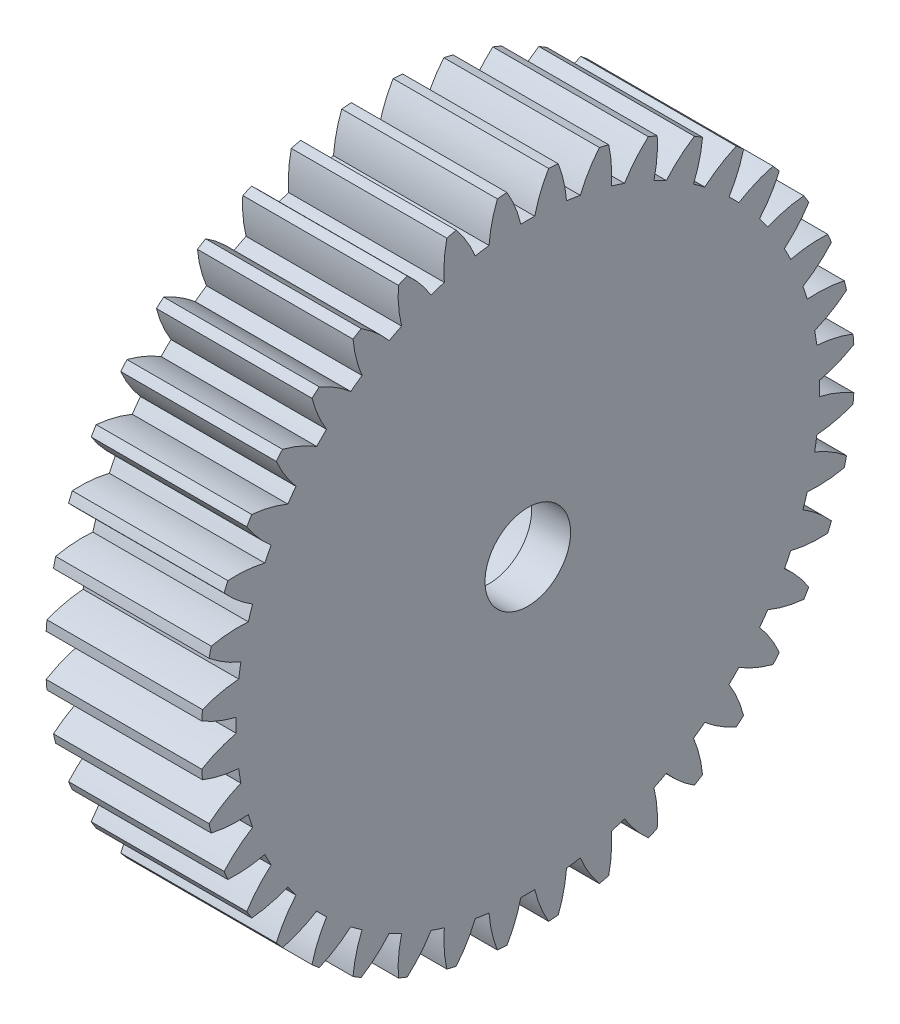
from build123d import *

# Parameters (mm, degrees)
SKETCH1_R           = 0.4
BOSS_EXTRUDE1_DEPTH = 3
SKETCH4_R           = 2.55
CUT_EXTRUDE2_DEPTH  = 4
BOSS_EXTRUDE2_DEPTH = 1
SKETCH6_R           = 1.1
CUT_EXTRUDE4_DEPTH  = 2


with BuildPart() as part:
    # Sketch1 → Boss-Extrude1 (new body)
    with BuildSketch(Plane(origin=(-1.595003587, 0, 0), x_dir=(0, 0, -1), z_dir=(1, 0, 0))):
        with BuildLine():
            ThreePointArc((-8.382899086, 0.535726523), (-7.953265869, 0.324118302), (-7.496863358, 0.178999427))
            ThreePointArc((-7.496863358, 0.178999427), (-7.499, 0), (-7.496863358, -0.178999427))
            ThreePointArc((-7.496863358, -0.178999427), (-7.953265869, -0.324118302), (-8.382899086, -0.535726523))
            ThreePointArc((-8.382899086, -0.535726523), (-8.374105603, -0.659056404), (-8.36349778, -0.782243493))
            ThreePointArc((-8.36349778, -0.782243493), (-7.906051242, -0.924037024), (-7.432566209, -0.995972162))
            ThreePointArc((-7.432566209, -0.995972162), (-7.406674866, -1.173102053), (-7.37656285, -1.349563456))
            ThreePointArc((-7.37656285, -1.349563456), (-7.804644696, -1.564292759), (-8.195885596, -1.840505175))
            ThreePointArc((-8.195885596, -1.840505175), (-8.167907331, -1.960941056), (-8.138159402, -2.080952079))
            ThreePointArc((-8.138159402, -2.080952079), (-7.664163394, -2.149439492), (-7.185254613, -2.146419611))
            ThreePointArc((-7.185254613, -2.146419611), (-7.131972816, -2.317318441), (-7.074626883, -2.486896753))
            ThreePointArc((-7.074626883, -2.486896753), (-7.463847268, -2.765949137), (-7.807062202, -3.099964481))
            ThreePointArc((-7.807062202, -3.099964481), (-7.760588073, -3.214540832), (-7.71243253, -3.328420718))
            ThreePointArc((-7.71243253, -3.328420718), (-7.233558408, -3.321915625), (-6.761018202, -3.244015085))
            ThreePointArc((-6.761018202, -3.244015085), (-6.681657925, -3.404474758), (-6.598490123, -3.562994399))
            ThreePointArc((-6.598490123, -3.562994399), (-6.939265149, -3.899498668), (-7.226003026, -4.283092373))
            ThreePointArc((-7.226003026, -4.283092373), (-7.162177381, -4.388987944), (-7.096799973, -4.493932593))
            ThreePointArc((-7.096799973, -4.493932593), (-6.624839207, -4.412595171), (-6.170303084, -4.261732142))
            ThreePointArc((-6.170303084, -4.261732142), (-6.066818441, -4.407801607), (-5.959876638, -4.551359298))
            ThreePointArc((-5.959876638, -4.551359298), (-6.243815291, -4.9370296), (-6.467015673, -5.360756316))
            ThreePointArc((-6.467015673, -5.360756316), (-6.387410111, -5.455363606), (-6.306420647, -5.548788933))
            ThreePointArc((-6.306420647, -5.548788933), (-5.852994478, -5.39462198), (-5.427654626, -5.174511209))
            ThreePointArc((-5.427654626, -5.174511209), (-5.302593752, -5.302593752), (-5.174511209, -5.427654626))
            ThreePointArc((-5.174511209, -5.427654626), (-5.39462198, -5.852994478), (-5.548788933, -6.306420647))
            ThreePointArc((-5.548788933, -6.306420647), (-5.455363606, -6.387410111), (-5.360756316, -6.467015673))
            ThreePointArc((-5.360756316, -6.467015673), (-4.9370296, -6.243815291), (-4.551359298, -5.959876638))
            ThreePointArc((-4.551359298, -5.959876638), (-4.407801607, -6.066818441), (-4.261732142, -6.170303084))
            ThreePointArc((-4.261732142, -6.170303084), (-4.412595171, -6.624839207), (-4.493932593, -7.096799973))
            ThreePointArc((-4.493932593, -7.096799973), (-4.388987944, -7.162177381), (-4.283092373, -7.226003026))
            ThreePointArc((-4.283092373, -7.226003026), (-3.899498668, -6.939265149), (-3.562994399, -6.598490123))
            ThreePointArc((-3.562994399, -6.598490123), (-3.404474758, -6.681657925), (-3.244015085, -6.761018202))
            ThreePointArc((-3.244015085, -6.761018202), (-3.321915625, -7.233558408), (-3.328420718, -7.71243253))
            ThreePointArc((-3.328420718, -7.71243253), (-3.214540832, -7.760588073), (-3.099964481, -7.807062202))
            ThreePointArc((-3.099964481, -7.807062202), (-2.765949137, -7.463847268), (-2.486896753, -7.074626883))
            ThreePointArc((-2.486896753, -7.074626883), (-2.317318441, -7.131972816), (-2.146419611, -7.185254613))
            ThreePointArc((-2.146419611, -7.185254613), (-2.149439492, -7.664163394), (-2.080952079, -8.138159402))
            ThreePointArc((-2.080952079, -8.138159402), (-1.960941056, -8.167907331), (-1.840505175, -8.195885596))
            ThreePointArc((-1.840505175, -8.195885596), (-1.564292759, -7.804644696), (-1.349563456, -7.37656285))
            ThreePointArc((-1.349563456, -7.37656285), (-1.173102053, -7.406674866), (-0.995972162, -7.432566209))
            ThreePointArc((-0.995972162, -7.432566209), (-0.924037024, -7.906051242), (-0.782243493, -8.36349778))
            ThreePointArc((-0.782243493, -8.36349778), (-0.659056404, -8.374105603), (-0.535726523, -8.382899086))
            ThreePointArc((-0.535726523, -8.382899086), (-0.324118302, -7.953265869), (-0.178999427, -7.496863358))
            ThreePointArc((-0.178999427, -7.496863358), (0, -7.499), (0.178999427, -7.496863358))
            ThreePointArc((0.178999427, -7.496863358), (0.324118302, -7.953265869), (0.535726523, -8.382899086))
            ThreePointArc((0.535726523, -8.382899086), (0.659056404, -8.374105603), (0.782243493, -8.36349778))
            ThreePointArc((0.782243493, -8.36349778), (0.924037024, -7.906051242), (0.995972162, -7.432566209))
            ThreePointArc((0.995972162, -7.432566209), (1.173102053, -7.406674866), (1.349563456, -7.37656285))
            ThreePointArc((1.349563456, -7.37656285), (1.564292759, -7.804644696), (1.840505175, -8.195885596))
            ThreePointArc((1.840505175, -8.195885596), (1.960941056, -8.167907331), (2.080952079, -8.138159402))
            ThreePointArc((2.080952079, -8.138159402), (2.149439492, -7.664163394), (2.146419611, -7.185254613))
            ThreePointArc((2.146419611, -7.185254613), (2.317318441, -7.131972816), (2.486896753, -7.074626883))
            ThreePointArc((2.486896753, -7.074626883), (2.765949137, -7.463847268), (3.099964481, -7.807062202))
            ThreePointArc((3.099964481, -7.807062202), (3.214540832, -7.760588073), (3.328420718, -7.71243253))
            ThreePointArc((3.328420718, -7.71243253), (3.321915625, -7.233558408), (3.244015085, -6.761018202))
            ThreePointArc((3.244015085, -6.761018202), (3.404474758, -6.681657925), (3.562994399, -6.598490123))
            ThreePointArc((3.562994399, -6.598490123), (3.899498668, -6.939265149), (4.283092373, -7.226003026))
            ThreePointArc((4.283092373, -7.226003026), (4.388987944, -7.162177381), (4.493932593, -7.096799973))
            ThreePointArc((4.493932593, -7.096799973), (4.412595171, -6.624839207), (4.261732142, -6.170303084))
            ThreePointArc((4.261732142, -6.170303084), (4.407801607, -6.066818441), (4.551359298, -5.959876638))
            ThreePointArc((4.551359298, -5.959876638), (4.9370296, -6.243815291), (5.360756316, -6.467015673))
            ThreePointArc((5.360756316, -6.467015673), (5.455363606, -6.387410111), (5.548788933, -6.306420647))
            ThreePointArc((5.548788933, -6.306420647), (5.39462198, -5.852994478), (5.174511209, -5.427654626))
            ThreePointArc((5.174511209, -5.427654626), (5.302593752, -5.302593752), (5.427654626, -5.174511209))
            ThreePointArc((5.427654626, -5.174511209), (5.852994478, -5.39462198), (6.306420647, -5.548788933))
            ThreePointArc((6.306420647, -5.548788933), (6.387410111, -5.455363606), (6.467015673, -5.360756316))
            ThreePointArc((6.467015673, -5.360756316), (6.243815291, -4.9370296), (5.959876638, -4.551359298))
            ThreePointArc((5.959876638, -4.551359298), (6.066818441, -4.407801607), (6.170303084, -4.261732142))
            ThreePointArc((6.170303084, -4.261732142), (6.624839207, -4.412595171), (7.096799973, -4.493932593))
            ThreePointArc((7.096799973, -4.493932593), (7.162177381, -4.388987944), (7.226003026, -4.283092373))
            ThreePointArc((7.226003026, -4.283092373), (6.939265149, -3.899498668), (6.598490123, -3.562994399))
            ThreePointArc((6.598490123, -3.562994399), (6.681657925, -3.404474758), (6.761018202, -3.244015085))
            ThreePointArc((6.761018202, -3.244015085), (7.233558408, -3.321915625), (7.71243253, -3.328420718))
            ThreePointArc((7.71243253, -3.328420718), (7.760588073, -3.214540832), (7.807062202, -3.099964481))
            ThreePointArc((7.807062202, -3.099964481), (7.463847268, -2.765949137), (7.074626883, -2.486896753))
            ThreePointArc((7.074626883, -2.486896753), (7.131972816, -2.317318441), (7.185254613, -2.146419611))
            ThreePointArc((7.185254613, -2.146419611), (7.664163394, -2.149439492), (8.138159402, -2.080952079))
            ThreePointArc((8.138159402, -2.080952079), (8.167907331, -1.960941056), (8.195885596, -1.840505175))
            ThreePointArc((8.195885596, -1.840505175), (7.804644696, -1.564292759), (7.37656285, -1.349563456))
            ThreePointArc((7.37656285, -1.349563456), (7.406674866, -1.173102053), (7.432566209, -0.995972162))
            ThreePointArc((7.432566209, -0.995972162), (7.906051242, -0.924037024), (8.36349778, -0.782243493))
            ThreePointArc((8.36349778, -0.782243493), (8.374105603, -0.659056404), (8.382899086, -0.535726523))
            ThreePointArc((8.382899086, -0.535726523), (7.953265869, -0.324118302), (7.496863358, -0.178999427))
            ThreePointArc((7.496863358, -0.178999427), (7.499, 0), (7.496863358, 0.178999427))
            ThreePointArc((7.496863358, 0.178999427), (7.953265869, 0.324118302), (8.382899086, 0.535726523))
            ThreePointArc((8.382899086, 0.535726523), (8.374105603, 0.659056404), (8.36349778, 0.782243493))
            ThreePointArc((8.36349778, 0.782243493), (7.906051242, 0.924037024), (7.432566209, 0.995972162))
            ThreePointArc((7.432566209, 0.995972162), (7.406674866, 1.173102053), (7.37656285, 1.349563456))
            ThreePointArc((7.37656285, 1.349563456), (7.804644696, 1.564292759), (8.195885596, 1.840505175))
            ThreePointArc((8.195885596, 1.840505175), (8.167907331, 1.960941056), (8.138159402, 2.080952079))
            ThreePointArc((8.138159402, 2.080952079), (7.664163394, 2.149439492), (7.185254613, 2.146419611))
            ThreePointArc((7.185254613, 2.146419611), (7.131972816, 2.317318441), (7.074626883, 2.486896753))
            ThreePointArc((7.074626883, 2.486896753), (7.463847268, 2.765949137), (7.807062202, 3.099964481))
            ThreePointArc((7.807062202, 3.099964481), (7.760588073, 3.214540832), (7.71243253, 3.328420718))
            ThreePointArc((7.71243253, 3.328420718), (7.233558408, 3.321915625), (6.761018202, 3.244015085))
            ThreePointArc((6.761018202, 3.244015085), (6.681657925, 3.404474758), (6.598490123, 3.562994399))
            ThreePointArc((6.598490123, 3.562994399), (6.939265149, 3.899498668), (7.226003026, 4.283092373))
            ThreePointArc((7.226003026, 4.283092373), (7.162177381, 4.388987944), (7.096799973, 4.493932593))
            ThreePointArc((7.096799973, 4.493932593), (6.624839207, 4.412595171), (6.170303084, 4.261732142))
            ThreePointArc((6.170303084, 4.261732142), (6.066818441, 4.407801607), (5.959876638, 4.551359298))
            ThreePointArc((5.959876638, 4.551359298), (6.243815291, 4.9370296), (6.467015673, 5.360756316))
            ThreePointArc((6.467015673, 5.360756316), (6.387410111, 5.455363606), (6.306420647, 5.548788933))
            ThreePointArc((6.306420647, 5.548788933), (5.852994478, 5.39462198), (5.427654626, 5.174511209))
            ThreePointArc((5.427654626, 5.174511209), (5.302593752, 5.302593752), (5.174511209, 5.427654626))
            ThreePointArc((5.174511209, 5.427654626), (5.39462198, 5.852994478), (5.548788933, 6.306420647))
            ThreePointArc((5.548788933, 6.306420647), (5.455363606, 6.387410111), (5.360756316, 6.467015673))
            ThreePointArc((5.360756316, 6.467015673), (4.9370296, 6.243815291), (4.551359298, 5.959876638))
            ThreePointArc((4.551359298, 5.959876638), (4.407801607, 6.066818441), (4.261732142, 6.170303084))
            ThreePointArc((4.261732142, 6.170303084), (4.412595171, 6.624839207), (4.493932593, 7.096799973))
            ThreePointArc((4.493932593, 7.096799973), (4.388987944, 7.162177381), (4.283092373, 7.226003026))
            ThreePointArc((4.283092373, 7.226003026), (3.899498668, 6.939265149), (3.562994399, 6.598490123))
            ThreePointArc((3.562994399, 6.598490123), (3.404474758, 6.681657925), (3.244015085, 6.761018202))
            ThreePointArc((3.244015085, 6.761018202), (3.321915625, 7.233558408), (3.328420718, 7.71243253))
            ThreePointArc((3.328420718, 7.71243253), (3.214540832, 7.760588073), (3.099964481, 7.807062202))
            ThreePointArc((3.099964481, 7.807062202), (2.765949137, 7.463847268), (2.486896753, 7.074626883))
            ThreePointArc((2.486896753, 7.074626883), (2.317318441, 7.131972816), (2.146419611, 7.185254613))
            ThreePointArc((2.146419611, 7.185254613), (2.149439492, 7.664163394), (2.080952079, 8.138159402))
            ThreePointArc((2.080952079, 8.138159402), (1.960941056, 8.167907331), (1.840505175, 8.195885596))
            ThreePointArc((1.840505175, 8.195885596), (1.564292759, 7.804644696), (1.349563456, 7.37656285))
            ThreePointArc((1.349563456, 7.37656285), (1.173102053, 7.406674866), (0.995972162, 7.432566209))
            ThreePointArc((0.995972162, 7.432566209), (0.924037024, 7.906051242), (0.782243493, 8.36349778))
            ThreePointArc((0.782243493, 8.36349778), (0.659056404, 8.374105603), (0.535726523, 8.382899086))
            ThreePointArc((0.535726523, 8.382899086), (0.324118302, 7.953265869), (0.178999427, 7.496863358))
            ThreePointArc((0.178999427, 7.496863358), (0, 7.499), (-0.178999427, 7.496863358))
            ThreePointArc((-0.178999427, 7.496863358), (-0.324118302, 7.953265869), (-0.535726523, 8.382899086))
            ThreePointArc((-0.535726523, 8.382899086), (-0.659056404, 8.374105603), (-0.782243493, 8.36349778))
            ThreePointArc((-0.782243493, 8.36349778), (-0.924037024, 7.906051242), (-0.995972162, 7.432566209))
            ThreePointArc((-0.995972162, 7.432566209), (-1.173102053, 7.406674866), (-1.349563456, 7.37656285))
            ThreePointArc((-1.349563456, 7.37656285), (-1.564292759, 7.804644696), (-1.840505175, 8.195885596))
            ThreePointArc((-1.840505175, 8.195885596), (-1.960941056, 8.167907331), (-2.080952079, 8.138159402))
            ThreePointArc((-2.080952079, 8.138159402), (-2.149439492, 7.664163394), (-2.146419611, 7.185254613))
            ThreePointArc((-2.146419611, 7.185254613), (-2.317318441, 7.131972816), (-2.486896753, 7.074626883))
            ThreePointArc((-2.486896753, 7.074626883), (-2.765949137, 7.463847268), (-3.099964481, 7.807062202))
            ThreePointArc((-3.099964481, 7.807062202), (-3.214540832, 7.760588073), (-3.328420718, 7.71243253))
            ThreePointArc((-3.328420718, 7.71243253), (-3.321915625, 7.233558408), (-3.244015085, 6.761018202))
            ThreePointArc((-3.244015085, 6.761018202), (-3.404474758, 6.681657925), (-3.562994399, 6.598490123))
            ThreePointArc((-3.562994399, 6.598490123), (-3.899498668, 6.939265149), (-4.283092373, 7.226003026))
            ThreePointArc((-4.283092373, 7.226003026), (-4.388987944, 7.162177381), (-4.493932593, 7.096799973))
            ThreePointArc((-4.493932593, 7.096799973), (-4.412595171, 6.624839207), (-4.261732142, 6.170303084))
            ThreePointArc((-4.261732142, 6.170303084), (-4.407801607, 6.066818441), (-4.551359298, 5.959876638))
            ThreePointArc((-4.551359298, 5.959876638), (-4.9370296, 6.243815291), (-5.360756316, 6.467015673))
            ThreePointArc((-5.360756316, 6.467015673), (-5.455363606, 6.387410111), (-5.548788933, 6.306420647))
            ThreePointArc((-5.548788933, 6.306420647), (-5.39462198, 5.852994478), (-5.174511209, 5.427654626))
            ThreePointArc((-5.174511209, 5.427654626), (-5.302593752, 5.302593752), (-5.427654626, 5.174511209))
            ThreePointArc((-5.427654626, 5.174511209), (-5.852994478, 5.39462198), (-6.306420647, 5.548788933))
            ThreePointArc((-6.306420647, 5.548788933), (-6.387410111, 5.455363606), (-6.467015673, 5.360756316))
            ThreePointArc((-6.467015673, 5.360756316), (-6.243815291, 4.9370296), (-5.959876638, 4.551359298))
            ThreePointArc((-5.959876638, 4.551359298), (-6.066818441, 4.407801607), (-6.170303084, 4.261732142))
            ThreePointArc((-6.170303084, 4.261732142), (-6.624839207, 4.412595171), (-7.096799973, 4.493932593))
            ThreePointArc((-7.096799973, 4.493932593), (-7.162177381, 4.388987944), (-7.226003026, 4.283092373))
            ThreePointArc((-7.226003026, 4.283092373), (-6.939265149, 3.899498668), (-6.598490123, 3.562994399))
            ThreePointArc((-6.598490123, 3.562994399), (-6.681657925, 3.404474758), (-6.761018202, 3.244015085))
            ThreePointArc((-6.761018202, 3.244015085), (-7.233558408, 3.321915625), (-7.71243253, 3.328420718))
            ThreePointArc((-7.71243253, 3.328420718), (-7.760588073, 3.214540832), (-7.807062202, 3.099964481))
            ThreePointArc((-7.807062202, 3.099964481), (-7.463847268, 2.765949137), (-7.074626883, 2.486896753))
            ThreePointArc((-7.074626883, 2.486896753), (-7.131972816, 2.317318441), (-7.185254613, 2.146419611))
            ThreePointArc((-7.185254613, 2.146419611), (-7.664163394, 2.149439492), (-8.138159402, 2.080952079))
            ThreePointArc((-8.138159402, 2.080952079), (-8.167907331, 1.960941056), (-8.195885596, 1.840505175))
            ThreePointArc((-8.195885596, 1.840505175), (-7.804644696, 1.564292759), (-7.37656285, 1.349563456))
            ThreePointArc((-7.37656285, 1.349563456), (-7.406674866, 1.173102053), (-7.432566209, 0.995972162))
            ThreePointArc((-7.432566209, 0.995972162), (-7.906051242, 0.924037024), (-8.36349778, 0.782243493))
            ThreePointArc((-8.36349778, 0.782243493), (-8.374105603, 0.659056404), (-8.382899086, 0.535726523))
        make_face()
        Circle(SKETCH1_R, mode=Mode.SUBTRACT)
    extrude(amount=-BOSS_EXTRUDE1_DEPTH)

    # Sketch4 → Cut-Extrude2 (cut, through all)
    with BuildSketch(Plane(origin=(-1.595003587, 0, 0), x_dir=(0, 0, -1), z_dir=(1, 0, 0))):
        Circle(SKETCH4_R)
    extrude(amount=-CUT_EXTRUDE2_DEPTH, mode=Mode.SUBTRACT)

    # Sketch5 → Boss-Extrude2 (add)
    with BuildSketch(Plane(origin=(-1.595003587, 0, 0), x_dir=(0, 0, -1), z_dir=(1, 0, 0))):
        with BuildLine():
            ThreePointArc((-8.36349778, 0.782243493), (-8.374105603, 0.659056404), (-8.382899086, 0.535726523))
            ThreePointArc((-8.382899086, 0.535726523), (-7.953265869, 0.324118302), (-7.496863358, 0.178999427))
            ThreePointArc((-7.496863358, 0.178999427), (-7.499, 0), (-7.496863358, -0.178999427))
            ThreePointArc((-7.496863358, -0.178999427), (-7.953265869, -0.324118302), (-8.382899086, -0.535726523))
            ThreePointArc((-8.382899086, -0.535726523), (-8.374105603, -0.659056404), (-8.36349778, -0.782243493))
            ThreePointArc((-8.36349778, -0.782243493), (-7.906051242, -0.924037024), (-7.432566209, -0.995972162))
            ThreePointArc((-7.432566209, -0.995972162), (-7.406674866, -1.173102053), (-7.37656285, -1.349563456))
            ThreePointArc((-7.37656285, -1.349563456), (-7.804644696, -1.564292759), (-8.195885596, -1.840505175))
            ThreePointArc((-8.195885596, -1.840505175), (-8.167907331, -1.960941056), (-8.138159402, -2.080952079))
            ThreePointArc((-8.138159402, -2.080952079), (-7.664163394, -2.149439492), (-7.185254613, -2.146419611))
            ThreePointArc((-7.185254613, -2.146419611), (-7.131972816, -2.317318441), (-7.074626883, -2.486896753))
            ThreePointArc((-7.074626883, -2.486896753), (-7.463847268, -2.765949137), (-7.807062202, -3.099964481))
            ThreePointArc((-7.807062202, -3.099964481), (-7.760588073, -3.214540832), (-7.71243253, -3.328420718))
            ThreePointArc((-7.71243253, -3.328420718), (-7.233558408, -3.321915625), (-6.761018202, -3.244015085))
            ThreePointArc((-6.761018202, -3.244015085), (-6.681657925, -3.404474758), (-6.598490123, -3.562994399))
            ThreePointArc((-6.598490123, -3.562994399), (-6.939265149, -3.899498668), (-7.226003026, -4.283092373))
            ThreePointArc((-7.226003026, -4.283092373), (-7.162177381, -4.388987944), (-7.096799973, -4.493932593))
            ThreePointArc((-7.096799973, -4.493932593), (-6.624839207, -4.412595171), (-6.170303084, -4.261732142))
            ThreePointArc((-6.170303084, -4.261732142), (-6.066818441, -4.407801607), (-5.959876638, -4.551359298))
            ThreePointArc((-5.959876638, -4.551359298), (-6.243815291, -4.9370296), (-6.467015673, -5.360756316))
            ThreePointArc((-6.467015673, -5.360756316), (-6.387410111, -5.455363606), (-6.306420647, -5.548788933))
            ThreePointArc((-6.306420647, -5.548788933), (-5.852994478, -5.39462198), (-5.427654626, -5.174511209))
            ThreePointArc((-5.427654626, -5.174511209), (-5.302593752, -5.302593752), (-5.174511209, -5.427654626))
            ThreePointArc((-5.174511209, -5.427654626), (-5.39462198, -5.852994478), (-5.548788933, -6.306420647))
            ThreePointArc((-5.548788933, -6.306420647), (-5.455363606, -6.387410111), (-5.360756316, -6.467015673))
            ThreePointArc((-5.360756316, -6.467015673), (-4.9370296, -6.243815291), (-4.551359298, -5.959876638))
            ThreePointArc((-4.551359298, -5.959876638), (-4.407801607, -6.066818441), (-4.261732142, -6.170303084))
            ThreePointArc((-4.261732142, -6.170303084), (-4.412595171, -6.624839207), (-4.493932593, -7.096799973))
            ThreePointArc((-4.493932593, -7.096799973), (-4.388987944, -7.162177381), (-4.283092373, -7.226003026))
            ThreePointArc((-4.283092373, -7.226003026), (-3.899498668, -6.939265149), (-3.562994399, -6.598490123))
            ThreePointArc((-3.562994399, -6.598490123), (-3.404474758, -6.681657925), (-3.244015085, -6.761018202))
            ThreePointArc((-3.244015085, -6.761018202), (-3.321915625, -7.233558408), (-3.328420718, -7.71243253))
            ThreePointArc((-3.328420718, -7.71243253), (-3.214540832, -7.760588073), (-3.099964481, -7.807062202))
            ThreePointArc((-3.099964481, -7.807062202), (-2.765949137, -7.463847268), (-2.486896753, -7.074626883))
            ThreePointArc((-2.486896753, -7.074626883), (-2.317318441, -7.131972816), (-2.146419611, -7.185254613))
            ThreePointArc((-2.146419611, -7.185254613), (-2.149439492, -7.664163394), (-2.080952079, -8.138159402))
            ThreePointArc((-2.080952079, -8.138159402), (-1.960941056, -8.167907331), (-1.840505175, -8.195885596))
            ThreePointArc((-1.840505175, -8.195885596), (-1.564292759, -7.804644696), (-1.349563456, -7.37656285))
            ThreePointArc((-1.349563456, -7.37656285), (-1.173102053, -7.406674866), (-0.995972162, -7.432566209))
            ThreePointArc((-0.995972162, -7.432566209), (-0.924037024, -7.906051242), (-0.782243493, -8.36349778))
            ThreePointArc((-0.782243493, -8.36349778), (-0.659056404, -8.374105603), (-0.535726523, -8.382899086))
            ThreePointArc((-0.535726523, -8.382899086), (-0.324118302, -7.953265869), (-0.178999427, -7.496863358))
            ThreePointArc((-0.178999427, -7.496863358), (0, -7.499), (0.178999427, -7.496863358))
            ThreePointArc((0.178999427, -7.496863358), (0.324118302, -7.953265869), (0.535726523, -8.382899086))
            ThreePointArc((0.535726523, -8.382899086), (0.659056404, -8.374105603), (0.782243493, -8.36349778))
            ThreePointArc((0.782243493, -8.36349778), (0.924037024, -7.906051242), (0.995972162, -7.432566209))
            ThreePointArc((0.995972162, -7.432566209), (1.173102053, -7.406674866), (1.349563456, -7.37656285))
            ThreePointArc((1.349563456, -7.37656285), (1.564292759, -7.804644696), (1.840505175, -8.195885596))
            ThreePointArc((1.840505175, -8.195885596), (1.960941056, -8.167907331), (2.080952079, -8.138159402))
            ThreePointArc((2.080952079, -8.138159402), (2.149439492, -7.664163394), (2.146419611, -7.185254613))
            ThreePointArc((2.146419611, -7.185254613), (2.317318441, -7.131972816), (2.486896753, -7.074626883))
            ThreePointArc((2.486896753, -7.074626883), (2.765949137, -7.463847268), (3.099964481, -7.807062202))
            ThreePointArc((3.099964481, -7.807062202), (3.214540832, -7.760588073), (3.328420718, -7.71243253))
            ThreePointArc((3.328420718, -7.71243253), (3.321915625, -7.233558408), (3.244015085, -6.761018202))
            ThreePointArc((3.244015085, -6.761018202), (3.404474758, -6.681657925), (3.562994399, -6.598490123))
            ThreePointArc((3.562994399, -6.598490123), (3.899498668, -6.939265149), (4.283092373, -7.226003026))
            ThreePointArc((4.283092373, -7.226003026), (4.388987944, -7.162177381), (4.493932593, -7.096799973))
            ThreePointArc((4.493932593, -7.096799973), (4.412595171, -6.624839207), (4.261732142, -6.170303084))
            ThreePointArc((4.261732142, -6.170303084), (4.407801607, -6.066818441), (4.551359298, -5.959876638))
            ThreePointArc((4.551359298, -5.959876638), (4.9370296, -6.243815291), (5.360756316, -6.467015673))
            ThreePointArc((5.360756316, -6.467015673), (5.455363606, -6.387410111), (5.548788933, -6.306420647))
            ThreePointArc((5.548788933, -6.306420647), (5.39462198, -5.852994478), (5.174511209, -5.427654626))
            ThreePointArc((5.174511209, -5.427654626), (5.302593752, -5.302593752), (5.427654626, -5.174511209))
            ThreePointArc((5.427654626, -5.174511209), (5.852994478, -5.39462198), (6.306420647, -5.548788933))
            ThreePointArc((6.306420647, -5.548788933), (6.387410111, -5.455363606), (6.467015673, -5.360756316))
            ThreePointArc((6.467015673, -5.360756316), (6.243815291, -4.9370296), (5.959876638, -4.551359298))
            ThreePointArc((5.959876638, -4.551359298), (6.066818441, -4.407801607), (6.170303084, -4.261732142))
            ThreePointArc((6.170303084, -4.261732142), (6.624839207, -4.412595171), (7.096799973, -4.493932593))
            ThreePointArc((7.096799973, -4.493932593), (7.162177381, -4.388987944), (7.226003026, -4.283092373))
            ThreePointArc((7.226003026, -4.283092373), (6.939265149, -3.899498668), (6.598490123, -3.562994399))
            ThreePointArc((6.598490123, -3.562994399), (6.681657925, -3.404474758), (6.761018202, -3.244015085))
            ThreePointArc((6.761018202, -3.244015085), (7.233558408, -3.321915625), (7.71243253, -3.328420718))
            ThreePointArc((7.71243253, -3.328420718), (7.760588073, -3.214540832), (7.807062202, -3.099964481))
            ThreePointArc((7.807062202, -3.099964481), (7.463847268, -2.765949137), (7.074626883, -2.486896753))
            ThreePointArc((7.074626883, -2.486896753), (7.131972816, -2.317318441), (7.185254613, -2.146419611))
            ThreePointArc((7.185254613, -2.146419611), (7.664163394, -2.149439492), (8.138159402, -2.080952079))
            ThreePointArc((8.138159402, -2.080952079), (8.167907331, -1.960941056), (8.195885596, -1.840505175))
            ThreePointArc((8.195885596, -1.840505175), (7.804644696, -1.564292759), (7.37656285, -1.349563456))
            ThreePointArc((7.37656285, -1.349563456), (7.406674866, -1.173102053), (7.432566209, -0.995972162))
            ThreePointArc((7.432566209, -0.995972162), (7.906051242, -0.924037024), (8.36349778, -0.782243493))
            ThreePointArc((8.36349778, -0.782243493), (8.374105603, -0.659056404), (8.382899086, -0.535726523))
            ThreePointArc((8.382899086, -0.535726523), (7.953265869, -0.324118302), (7.496863358, -0.178999427))
            ThreePointArc((7.496863358, -0.178999427), (7.499, 0), (7.496863358, 0.178999427))
            ThreePointArc((7.496863358, 0.178999427), (7.953265869, 0.324118302), (8.382899086, 0.535726523))
            ThreePointArc((8.382899086, 0.535726523), (8.374105603, 0.659056404), (8.36349778, 0.782243493))
            ThreePointArc((8.36349778, 0.782243493), (7.906051242, 0.924037024), (7.432566209, 0.995972162))
            ThreePointArc((7.432566209, 0.995972162), (7.406674866, 1.173102053), (7.37656285, 1.349563456))
            ThreePointArc((7.37656285, 1.349563456), (7.804644696, 1.564292759), (8.195885596, 1.840505175))
            ThreePointArc((8.195885596, 1.840505175), (8.167907331, 1.960941056), (8.138159402, 2.080952079))
            ThreePointArc((8.138159402, 2.080952079), (7.664163394, 2.149439492), (7.185254613, 2.146419611))
            ThreePointArc((7.185254613, 2.146419611), (7.131972816, 2.317318441), (7.074626883, 2.486896753))
            ThreePointArc((7.074626883, 2.486896753), (7.463847268, 2.765949137), (7.807062202, 3.099964481))
            ThreePointArc((7.807062202, 3.099964481), (7.760588073, 3.214540832), (7.71243253, 3.328420718))
            ThreePointArc((7.71243253, 3.328420718), (7.233558408, 3.321915625), (6.761018202, 3.244015085))
            ThreePointArc((6.761018202, 3.244015085), (6.681657925, 3.404474758), (6.598490123, 3.562994399))
            ThreePointArc((6.598490123, 3.562994399), (6.939265149, 3.899498668), (7.226003026, 4.283092373))
            ThreePointArc((7.226003026, 4.283092373), (7.162177381, 4.388987944), (7.096799973, 4.493932593))
            ThreePointArc((7.096799973, 4.493932593), (6.624839207, 4.412595171), (6.170303084, 4.261732142))
            ThreePointArc((6.170303084, 4.261732142), (6.066818441, 4.407801607), (5.959876638, 4.551359298))
            ThreePointArc((5.959876638, 4.551359298), (6.243815291, 4.9370296), (6.467015673, 5.360756316))
            ThreePointArc((6.467015673, 5.360756316), (6.387410111, 5.455363606), (6.306420647, 5.548788933))
            ThreePointArc((6.306420647, 5.548788933), (5.852994478, 5.39462198), (5.427654626, 5.174511209))
            ThreePointArc((5.427654626, 5.174511209), (5.302593752, 5.302593752), (5.174511209, 5.427654626))
            ThreePointArc((5.174511209, 5.427654626), (5.39462198, 5.852994478), (5.548788933, 6.306420647))
            ThreePointArc((5.548788933, 6.306420647), (5.455363606, 6.387410111), (5.360756316, 6.467015673))
            ThreePointArc((5.360756316, 6.467015673), (4.9370296, 6.243815291), (4.551359298, 5.959876638))
            ThreePointArc((4.551359298, 5.959876638), (4.407801607, 6.066818441), (4.261732142, 6.170303084))
            ThreePointArc((4.261732142, 6.170303084), (4.412595171, 6.624839207), (4.493932593, 7.096799973))
            ThreePointArc((4.493932593, 7.096799973), (4.388987944, 7.162177381), (4.283092373, 7.226003026))
            ThreePointArc((4.283092373, 7.226003026), (3.899498668, 6.939265149), (3.562994399, 6.598490123))
            ThreePointArc((3.562994399, 6.598490123), (3.404474758, 6.681657925), (3.244015085, 6.761018202))
            ThreePointArc((3.244015085, 6.761018202), (3.321915625, 7.233558408), (3.328420718, 7.71243253))
            ThreePointArc((3.328420718, 7.71243253), (3.214540832, 7.760588073), (3.099964481, 7.807062202))
            ThreePointArc((3.099964481, 7.807062202), (2.765949137, 7.463847268), (2.486896753, 7.074626883))
            ThreePointArc((2.486896753, 7.074626883), (2.317318441, 7.131972816), (2.146419611, 7.185254613))
            ThreePointArc((2.146419611, 7.185254613), (2.149439492, 7.664163394), (2.080952079, 8.138159402))
            ThreePointArc((2.080952079, 8.138159402), (1.960941056, 8.167907331), (1.840505175, 8.195885596))
            ThreePointArc((1.840505175, 8.195885596), (1.564292759, 7.804644696), (1.349563456, 7.37656285))
            ThreePointArc((1.349563456, 7.37656285), (1.173102053, 7.406674866), (0.995972162, 7.432566209))
            ThreePointArc((0.995972162, 7.432566209), (0.924037024, 7.906051242), (0.782243493, 8.36349778))
            ThreePointArc((0.782243493, 8.36349778), (0.659056404, 8.374105603), (0.535726523, 8.382899086))
            ThreePointArc((0.535726523, 8.382899086), (0.324118302, 7.953265869), (0.178999427, 7.496863358))
            ThreePointArc((0.178999427, 7.496863358), (0, 7.499), (-0.178999427, 7.496863358))
            ThreePointArc((-0.178999427, 7.496863358), (-0.324118302, 7.953265869), (-0.535726523, 8.382899086))
            ThreePointArc((-0.535726523, 8.382899086), (-0.659056404, 8.374105603), (-0.782243493, 8.36349778))
            ThreePointArc((-0.782243493, 8.36349778), (-0.924037024, 7.906051242), (-0.995972162, 7.432566209))
            ThreePointArc((-0.995972162, 7.432566209), (-1.173102053, 7.406674866), (-1.349563456, 7.37656285))
            ThreePointArc((-1.349563456, 7.37656285), (-1.564292759, 7.804644696), (-1.840505175, 8.195885596))
            ThreePointArc((-1.840505175, 8.195885596), (-1.960941056, 8.167907331), (-2.080952079, 8.138159402))
            ThreePointArc((-2.080952079, 8.138159402), (-2.149439492, 7.664163394), (-2.146419611, 7.185254613))
            ThreePointArc((-2.146419611, 7.185254613), (-2.317318441, 7.131972816), (-2.486896753, 7.074626883))
            ThreePointArc((-2.486896753, 7.074626883), (-2.765949137, 7.463847268), (-3.099964481, 7.807062202))
            ThreePointArc((-3.099964481, 7.807062202), (-3.214540832, 7.760588073), (-3.328420718, 7.71243253))
            ThreePointArc((-3.328420718, 7.71243253), (-3.321915625, 7.233558408), (-3.244015085, 6.761018202))
            ThreePointArc((-3.244015085, 6.761018202), (-3.404474758, 6.681657925), (-3.562994399, 6.598490123))
            ThreePointArc((-3.562994399, 6.598490123), (-3.899498668, 6.939265149), (-4.283092373, 7.226003026))
            ThreePointArc((-4.283092373, 7.226003026), (-4.388987944, 7.162177381), (-4.493932593, 7.096799973))
            ThreePointArc((-4.493932593, 7.096799973), (-4.412595171, 6.624839207), (-4.261732142, 6.170303084))
            ThreePointArc((-4.261732142, 6.170303084), (-4.407801607, 6.066818441), (-4.551359298, 5.959876638))
            ThreePointArc((-4.551359298, 5.959876638), (-4.9370296, 6.243815291), (-5.360756316, 6.467015673))
            ThreePointArc((-5.360756316, 6.467015673), (-5.455363606, 6.387410111), (-5.548788933, 6.306420647))
            ThreePointArc((-5.548788933, 6.306420647), (-5.39462198, 5.852994478), (-5.174511209, 5.427654626))
            ThreePointArc((-5.174511209, 5.427654626), (-5.302593752, 5.302593752), (-5.427654626, 5.174511209))
            ThreePointArc((-5.427654626, 5.174511209), (-5.852994478, 5.39462198), (-6.306420647, 5.548788933))
            ThreePointArc((-6.306420647, 5.548788933), (-6.387410111, 5.455363606), (-6.467015673, 5.360756316))
            ThreePointArc((-6.467015673, 5.360756316), (-6.243815291, 4.9370296), (-5.959876638, 4.551359298))
            ThreePointArc((-5.959876638, 4.551359298), (-6.066818441, 4.407801607), (-6.170303084, 4.261732142))
            ThreePointArc((-6.170303084, 4.261732142), (-6.624839207, 4.412595171), (-7.096799973, 4.493932593))
            ThreePointArc((-7.096799973, 4.493932593), (-7.162177381, 4.388987944), (-7.226003026, 4.283092373))
            ThreePointArc((-7.226003026, 4.283092373), (-6.939265149, 3.899498668), (-6.598490123, 3.562994399))
            ThreePointArc((-6.598490123, 3.562994399), (-6.681657925, 3.404474758), (-6.761018202, 3.244015085))
            ThreePointArc((-6.761018202, 3.244015085), (-7.233558408, 3.321915625), (-7.71243253, 3.328420718))
            ThreePointArc((-7.71243253, 3.328420718), (-7.760588073, 3.214540832), (-7.807062202, 3.099964481))
            ThreePointArc((-7.807062202, 3.099964481), (-7.463847268, 2.765949137), (-7.074626883, 2.486896753))
            ThreePointArc((-7.074626883, 2.486896753), (-7.131972816, 2.317318441), (-7.185254613, 2.146419611))
            ThreePointArc((-7.185254613, 2.146419611), (-7.664163394, 2.149439492), (-8.138159402, 2.080952079))
            ThreePointArc((-8.138159402, 2.080952079), (-8.167907331, 1.960941056), (-8.195885596, 1.840505175))
            ThreePointArc((-8.195885596, 1.840505175), (-7.804644696, 1.564292759), (-7.37656285, 1.349563456))
            ThreePointArc((-7.37656285, 1.349563456), (-7.406674866, 1.173102053), (-7.432566209, 0.995972162))
            ThreePointArc((-7.432566209, 0.995972162), (-7.906051242, 0.924037024), (-8.36349778, 0.782243493))
        make_face()
    extrude(amount=BOSS_EXTRUDE2_DEPTH)

    # Sketch6 → Cut-Extrude4 (cut, through all)
    with BuildSketch(Plane(origin=(-1.595003587, 0, 0), x_dir=(0, 0, -1), z_dir=(1, 0, 0))):
        Circle(SKETCH6_R)
    extrude(amount=CUT_EXTRUDE4_DEPTH, mode=Mode.SUBTRACT)


solid = part.part
